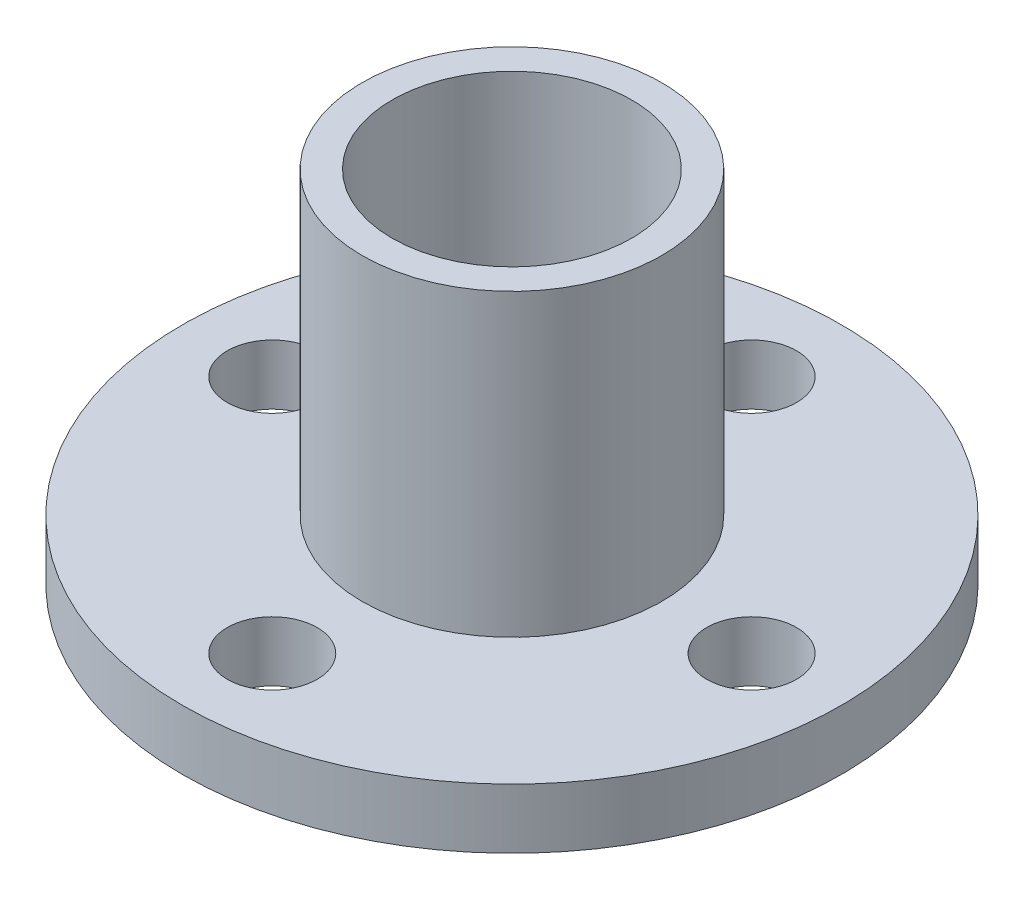
from build123d import *

# Parameters (mm, degrees)
SKETCH1_R           = 11
SKETCH1_R_2         = 1.5
SKETCH1_R_3         = 5
BOSS_EXTRUDE1_DEPTH = 2
SKETCH1_3_R         = 5
SKETCH1_3_R_2       = 4
BOSS_EXTRUDE2_DEPTH = 12


with BuildPart() as part:
    # Sketch1 → Boss-Extrude1 (new body)
    with BuildSketch(Plane(origin=(0, 0, 0), x_dir=(1, 0, 0), z_dir=(0, 1, 0))):
        Circle(SKETCH1_R)
        with Locations((0, -8)):
            Circle(SKETCH1_R_2, mode=Mode.SUBTRACT)
        with Locations((8, 0)):
            Circle(SKETCH1_R_2, mode=Mode.SUBTRACT)
        with Locations((-8, 0)):
            Circle(SKETCH1_R_2, mode=Mode.SUBTRACT)
        Circle(SKETCH1_R_3, mode=Mode.SUBTRACT)
        with Locations((0, 8)):
            Circle(SKETCH1_R_2, mode=Mode.SUBTRACT)
    extrude(amount=BOSS_EXTRUDE1_DEPTH)

    # Sketch1_3 → Boss-Extrude2 (add)
    with BuildSketch(Plane(origin=(0, 0, 0), x_dir=(1, 0, 0), z_dir=(0, 1, 0))):
        Circle(SKETCH1_3_R)
        Circle(SKETCH1_3_R_2, mode=Mode.SUBTRACT)
    extrude(amount=BOSS_EXTRUDE2_DEPTH)


solid = part.part
